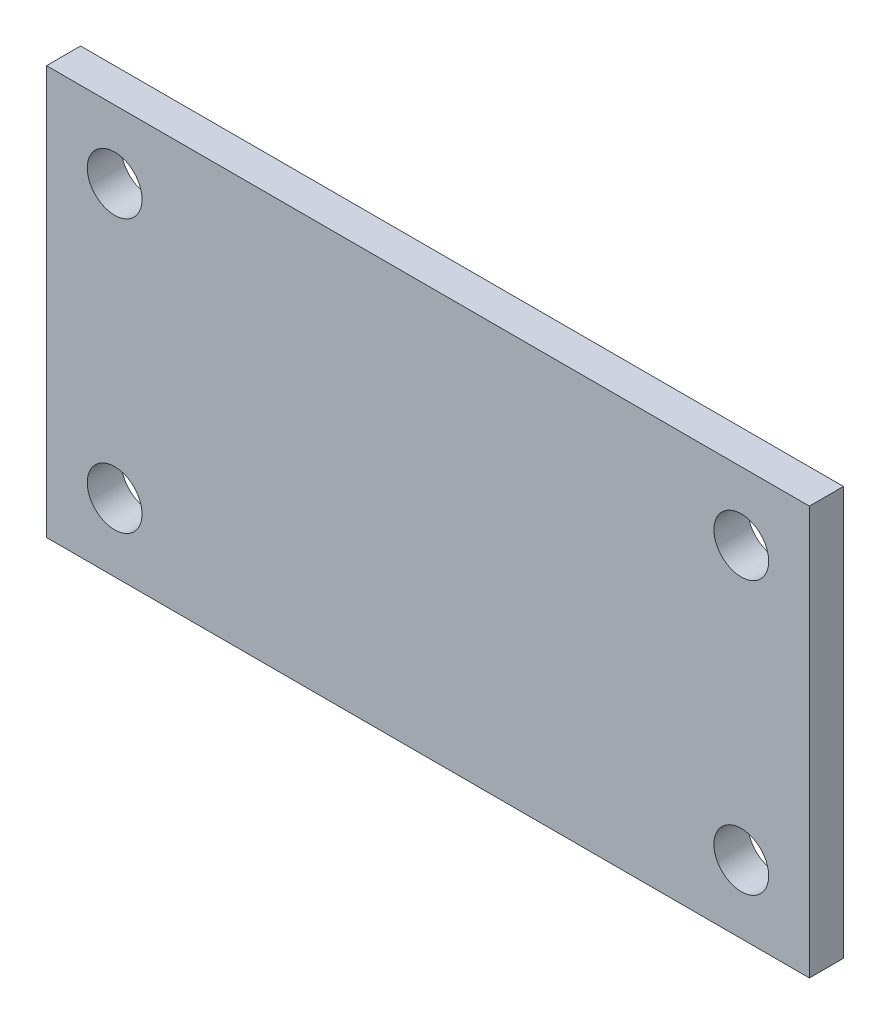
from build123d import *

# Parameters (mm, degrees)
SKETCH1_W           = 71.12
SKETCH1_H           = 38.1
BOSS_EXTRUDE1_DEPTH = 3.175
CUT_EXTRUDE1_REACH  = 5.175
SKETCH2_R           = 2.5527


with BuildPart() as part:
    # Sketch1 → Boss-Extrude1 (new body)
    with BuildSketch(Plane.XY):
        with Locations((35.56, 19.05)):
            Rectangle(SKETCH1_W, SKETCH1_H)
    extrude(amount=BOSS_EXTRUDE1_DEPTH)

    # Sketch2 → Cut-Extrude1 (cut, up to next)
    with BuildSketch(Plane(origin=(0, 0, 0), x_dir=(-1, 0, 0), z_dir=(0, 0, -1)), mode=Mode.PRIVATE) as cut_extrude1_sk1:
        with Locations((-6.35, 6.35)):
            Circle(SKETCH2_R)
    cut_extrude1_tool1 = extrude(cut_extrude1_sk1.sketch, amount=-CUT_EXTRUDE1_REACH, mode=Mode.PRIVATE) & part.part
    add(cut_extrude1_tool1.solids().sort_by_distance((6.35, 6.35, 0))[0], mode=Mode.SUBTRACT)
    # Sketch2 → Cut-Extrude1 (cut, up to next)
    with BuildSketch(Plane(origin=(0, 0, 0), x_dir=(-1, 0, 0), z_dir=(0, 0, -1)), mode=Mode.PRIVATE) as cut_extrude1_sk2:
        with Locations((-64.77, 6.35)):
            Circle(SKETCH2_R)
    cut_extrude1_tool2 = extrude(cut_extrude1_sk2.sketch, amount=-CUT_EXTRUDE1_REACH, mode=Mode.PRIVATE) & part.part
    add(cut_extrude1_tool2.solids().sort_by_distance((64.77, 6.35, 0))[0], mode=Mode.SUBTRACT)
    # Sketch2 → Cut-Extrude1 (cut, up to next)
    with BuildSketch(Plane(origin=(0, 0, 0), x_dir=(-1, 0, 0), z_dir=(0, 0, -1)), mode=Mode.PRIVATE) as cut_extrude1_sk3:
        with Locations((-64.77, 31.75)):
            Circle(SKETCH2_R)
    cut_extrude1_tool3 = extrude(cut_extrude1_sk3.sketch, amount=-CUT_EXTRUDE1_REACH, mode=Mode.PRIVATE) & part.part
    add(cut_extrude1_tool3.solids().sort_by_distance((64.77, 31.75, 0))[0], mode=Mode.SUBTRACT)
    # Sketch2 → Cut-Extrude1 (cut, up to next)
    with BuildSketch(Plane(origin=(0, 0, 0), x_dir=(-1, 0, 0), z_dir=(0, 0, -1)), mode=Mode.PRIVATE) as cut_extrude1_sk4:
        with Locations((-6.35, 31.75)):
            Circle(SKETCH2_R)
    cut_extrude1_tool4 = extrude(cut_extrude1_sk4.sketch, amount=-CUT_EXTRUDE1_REACH, mode=Mode.PRIVATE) & part.part
    add(cut_extrude1_tool4.solids().sort_by_distance((6.35, 31.75, 0))[0], mode=Mode.SUBTRACT)


solid = part.part
